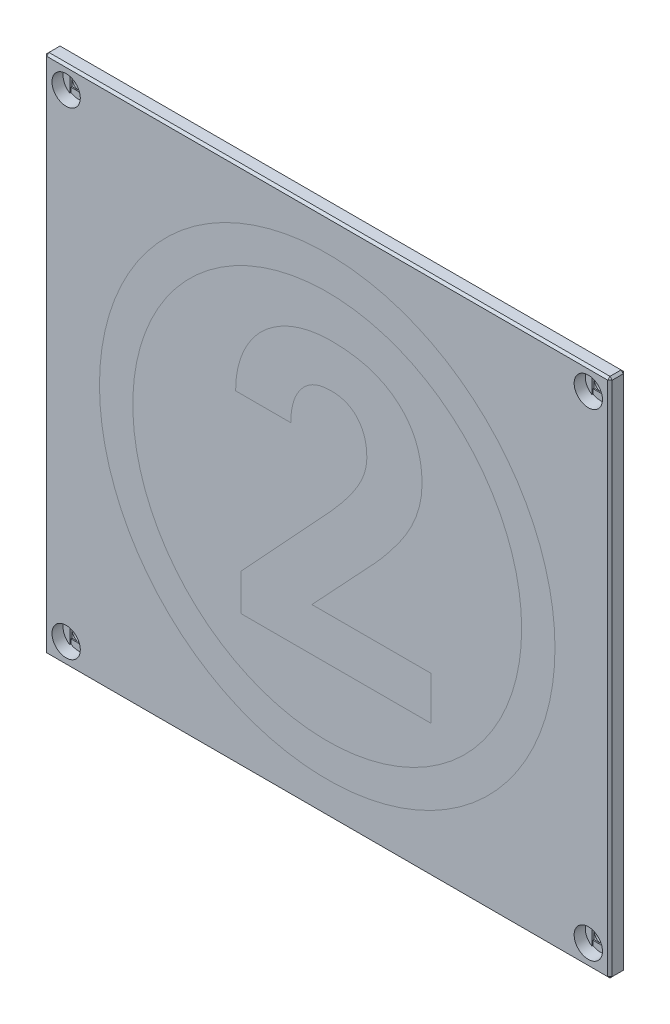
from build123d import *

# Parameters (mm, degrees)
SKETCH2_W               = 101.8
SKETCH2_H               = 93.8
SKETCH2_R               = 1.35
BOSS_EXTRUDE1_DEPTH     = 2.8
SKETCH3_R               = 2.55
CUT_EXTRUDE1_DEPTH      = 2
CUT_EXTRUDE2_DEPTH      = 0.2
SKETCH5_W               = 2.7
SKETCH5_H               = 2.7
CUT_EXTRUDE3_DEPTH      = 0.2
MIRROR2_COPY_1_DEPTH    = 0.2
MIRROR2_COPY_2_SKETCH_W = 2.7
MIRROR2_COPY_2_SKETCH_H = 2.7
MIRROR2_COPY_2_DEPTH    = 0.2
CHAMFER1_SIZE           = 0.4
SKETCH6_W               = 81.8
SKETCH6_H               = 73.8
CUT_EXTRUDE4_DEPTH      = 1.2
SKETCH7_R               = 41
SKETCH7_R_2             = 35
CUT_EXTRUDE5_DEPTH      = 1
SKETCH7_2_R             = 41
SKETCH7_2_R_2           = 35
BOSS_EXTRUDE2_DEPTH     = 1
CUT_EXTRUDE6_DEPTH      = 1
BOSS_EXTRUDE3_DEPTH     = 1


with BuildPart() as part:
    # Sketch2 → Boss-Extrude1 (new body)
    with BuildSketch(Plane.XY):
        with Locations((0, -6)):
            Rectangle(SKETCH2_W, SKETCH2_H)
        with Locations((-47, 37)):
            Circle(SKETCH2_R, mode=Mode.SUBTRACT)
        with Locations((47, 37)):
            Circle(SKETCH2_R, mode=Mode.SUBTRACT)
        with Locations((47, -49)):
            Circle(SKETCH2_R, mode=Mode.SUBTRACT)
        with Locations((-47, -49)):
            Circle(SKETCH2_R, mode=Mode.SUBTRACT)
    extrude(amount=BOSS_EXTRUDE1_DEPTH)

    # Sketch3 → Cut-Extrude1 (cut)
    with BuildSketch(Plane.XY.offset(2.8)):
        with Locations((-47, 37)):
            Circle(SKETCH3_R)
        with Locations((47, 37)):
            Circle(SKETCH3_R)
        with Locations((47, -49)):
            Circle(SKETCH3_R)
        with Locations((-47, -49)):
            Circle(SKETCH3_R)
    extrude(amount=-CUT_EXTRUDE1_DEPTH, mode=Mode.SUBTRACT)

    # Sketch4 → Cut-Extrude2 (cut)
    with BuildSketch(Plane.XY.offset(0.8)):
        with BuildLine():
            Line((-48.35, 34.836669235), (-48.35, 39.163330765))
            ThreePointArc((-48.35, 39.163330765), (-47, 39.55), (-45.65, 39.163330765))
            Line((-45.65, 39.163330765), (-45.65, 34.836669235))
            ThreePointArc((-45.65, 34.836669235), (-47, 34.45), (-48.35, 34.836669235))
        make_face()
    cut_extrude2 = extrude(amount=-CUT_EXTRUDE2_DEPTH, mode=Mode.SUBTRACT)

    # Sketch5 → Cut-Extrude3 (cut)
    with BuildSketch(Plane.XY.offset(0.6)):
        with Locations((-47, 37)):
            Rectangle(SKETCH5_W, SKETCH5_H)
    cut_extrude3 = extrude(amount=-CUT_EXTRUDE3_DEPTH, mode=Mode.SUBTRACT)

    # Mirror1: Cut-Extrude2, Cut-Extrude3 across plane
    add(cut_extrude2.mirror(Plane.ZX.offset(-6)), mode=Mode.SUBTRACT)
    add(cut_extrude3.mirror(Plane.ZX.offset(-6)), mode=Mode.SUBTRACT)

    # Mirror2: Cut-Extrude2, Cut-Extrude3 across plane
    add(cut_extrude2.mirror(Plane(origin=(0, 0, 0), x_dir=(0, 0, 1), z_dir=(1, 0, 0))), mode=Mode.SUBTRACT)
    add(cut_extrude3.mirror(Plane(origin=(0, 0, 0), x_dir=(0, 0, 1), z_dir=(1, 0, 0))), mode=Mode.SUBTRACT)

    # Mirror2 copy 1 sketch → Mirror2 copy 1 (cut)
    with BuildSketch(Plane(origin=(0, -12, 0.8), x_dir=(-1, 0, 0), z_dir=(0, 0, 1))):
        with BuildLine():
            Line((-48.35, 34.836669235), (-48.35, 39.163330765))
            ThreePointArc((-48.35, 39.163330765), (-47, 39.55), (-45.65, 39.163330765))
            Line((-45.65, 39.163330765), (-45.65, 34.836669235))
            ThreePointArc((-45.65, 34.836669235), (-47, 34.45), (-48.35, 34.836669235))
        make_face()
    extrude(amount=-MIRROR2_COPY_1_DEPTH, mode=Mode.SUBTRACT)

    # Mirror2 copy 2 sketch → Mirror2 copy 2 (cut)
    with BuildSketch(Plane(origin=(0, -12, 0.6), x_dir=(-1, 0, 0), z_dir=(0, 0, 1))):
        with Locations((-47, 37)):
            Rectangle(MIRROR2_COPY_2_SKETCH_W, MIRROR2_COPY_2_SKETCH_H)
    extrude(amount=-MIRROR2_COPY_2_DEPTH, mode=Mode.SUBTRACT)

    # Chamfer1
    chamfer1_edges = [part.edges().sort_by_distance(p)[0] for p in [
        (50.9, -6, 2.8),
        (0, 40.9, 2.8),
        (-50.9, -6, 2.8),
        (0, 40.9, 0),
        (50.9, -6, 0),
        (0, -52.9, 0),
        (-50.9, -6, 0),
        (-50.9, 40.9, 1.4),
        (50.9, 40.9, 1.4),
        (50.9, -52.9, 1.4),
        (-50.9, -52.9, 1.4),
        (0, -52.9, 2.8),
    ]]
    chamfer(chamfer1_edges, length=CHAMFER1_SIZE)

    # Sketch6 → Cut-Extrude4 (cut)
    with BuildSketch(Plane(origin=(0, 0, 0), x_dir=(-1, 0, 0), z_dir=(0, 0, -1))):
        with Locations((0, -6)):
            Rectangle(SKETCH6_W, SKETCH6_H)
    extrude(amount=-CUT_EXTRUDE4_DEPTH, mode=Mode.SUBTRACT)

    # Sketch7 → Cut-Extrude5 (cut)
    with BuildSketch(Plane.XY.offset(2.8)):
        with Locations((0, -6)):
            Circle(SKETCH7_R)
        with Locations((0, -6)):
            Circle(SKETCH7_R_2, mode=Mode.SUBTRACT)
    extrude(amount=-CUT_EXTRUDE5_DEPTH, mode=Mode.SUBTRACT)

    # Sketch8 → Cut-Extrude6 (cut)
    with BuildSketch(Plane.XY.offset(2.8)):
        with BuildLine():
            Line((18.671022727, -28.9), (-15.501055195, -28.9))
            Line((-15.501055195, -28.9), (-15.501055195, -22.274594156))
            Line((-15.501055195, -22.274594156), (0.63125, -4.884172078))
            add(Edge.make_bspline(
                [(0.63125, -4.884172078), (1.153277451, -4.292855043), (2.146557383, -3.167735389), (3.489118969, -1.506272711), (4.614642881, 0.038757574), (5.531438955, 1.477799135), (6.254834728, 2.841439855), (6.758035318, 4.1695038), (7.069448153, 5.467413282), (7.113481554, 6.32572019), (7.134902597, 6.743262987)],
                knots=[0, 0, 0, 0, 0.002366131, 0.004502121, 0.006405807, 0.008097562, 0.009617785, 0.011027364, 0.012349086, 0.013601174, 0.013601174, 0.013601174, 0.013601174], degree=3))
            add(Edge.make_bspline(
                [(7.134902597, 6.743262987), (7.118445512, 7.276005414), (7.087090374, 8.291021839), (6.769786109, 9.72439361), (6.241621668, 10.984152827), (5.60733002, 11.874698209), (5.028302195, 12.495851442), (4.530064095, 12.883158254), (3.995471939, 13.214394751), (3.418655987, 13.500854707), (2.788730275, 13.690966972), (2.122500599, 13.850084328), (1.408201929, 13.940647127), (0.915581702, 13.951532569), (0.661688312, 13.957142857)],
                knots=[0, 0, 0, 0, 0.001596166, 0.003041123, 0.004377369, 0.005666563, 0.006298071, 0.006919225, 0.007552686, 0.008183461, 0.008844439, 0.009521268, 0.010237342, 0.010998908, 0.010998908, 0.010998908, 0.010998908], degree=3))
            add(Edge.make_bspline(
                [(0.661688312, 13.957142857), (0.387329122, 13.949122126), (-0.146819306, 13.933506608), (-0.925115272, 13.818488237), (-1.657002545, 13.638358111), (-2.34656322, 13.3833698), (-2.99118454, 13.045988701), (-3.586094326, 12.627916029), (-4.144968715, 12.14576162), (-4.64669302, 11.586413684), (-5.102990563, 10.973785534), (-5.488156761, 10.302627713), (-5.829857506, 9.59447204), (-6.084904505, 8.827753466), (-6.304005462, 8.022940946), (-6.451792588, 7.170389323), (-6.546263196, 6.271919424), (-6.556889942, 5.657882139), (-6.562337662, 5.343100649)],
                knots=[0, 0, 0, 0, 0.000822836, 0.001601975, 0.002354977, 0.003080548, 0.003802135, 0.004531102, 0.005257453, 0.006011616, 0.006780715, 0.007544643, 0.008329836, 0.009135222, 0.0099646, 0.010830355, 0.011727869, 0.012671948, 0.012671948, 0.012671948, 0.012671948], degree=3))
            Line((-6.562337662, 5.343100649), (-16.495373377, 5.343100649))
            add(Edge.make_bspline(
                [(-16.495373377, 5.343100649), (-16.472833745, 6.089317638), (-16.428310573, 7.563341142), (-15.990087182, 9.712803635), (-15.323734547, 11.77162153), (-14.366953591, 13.70697381), (-13.160132284, 15.489920318), (-11.730459888, 17.097573105), (-10.051815444, 18.468784007), (-8.501752801, 19.449883434), (-7.166848132, 20.116905895), (-6.119646707, 20.555248133), (-5.039721957, 20.917594334), (-3.930506595, 21.227840696), (-2.783114737, 21.455409519), (-1.605298826, 21.630686517), (-0.39538628, 21.734275665), (0.421368014, 21.74428947), (0.834172078, 21.749350649)],
                knots=[0, 0, 0, 0, 0.002236036, 0.004416906, 0.006553763, 0.008713645, 0.010869232, 0.012995948, 0.01514333, 0.017350242, 0.018484611, 0.019617072, 0.020752892, 0.02189994, 0.023069958, 0.024259478, 0.02547112, 0.026709319, 0.026709319, 0.026709319, 0.026709319], degree=3))
            add(Edge.make_bspline(
                [(0.834172078, 21.749350649), (1.456907098, 21.737646404), (2.671022468, 21.714827221), (4.440562578, 21.538104219), (6.105120302, 21.263234511), (7.660848296, 20.855642003), (9.106919089, 20.326393159), (10.451070485, 19.688335577), (11.690955571, 18.93665069), (12.806890963, 18.056894891), (13.816455567, 17.089092945), (14.685863549, 16.007982115), (15.431503, 14.840733282), (16.033035825, 13.567820636), (16.497850687, 12.202229349), (16.834128553, 10.744393474), (17.024495809, 9.190124376), (17.053185494, 8.123647518), (17.067938312, 7.575243506)],
                knots=[0, 0, 0, 0, 0.001867875, 0.003641703, 0.005329742, 0.006924456, 0.008458767, 0.009942772, 0.011381838, 0.012798519, 0.014197689, 0.015568352, 0.016950384, 0.018343655, 0.019781111, 0.021270136, 0.022824346, 0.024469548, 0.024469548, 0.024469548, 0.024469548], degree=3))
            add(Edge.make_bspline(
                [(17.067938312, 7.575243506), (17.043098771, 6.95473273), (16.992757545, 5.697170305), (16.619494629, 3.806235067), (16.016153042, 1.897838615), (15.309531335, 0.31296178), (14.629099278, -0.985995249), (14.018070175, -2.011350852), (13.312994087, -3.069775085), (12.545269606, -4.186251153), (11.666914823, -5.32178064), (10.721490134, -6.516408603), (9.691781913, -7.752866399), (8.953838352, -8.57302218), (8.575649351, -8.993344156)],
                knots=[0, 0, 0, 0, 0.001860725, 0.00377105, 0.005760567, 0.007854945, 0.008966858, 0.010158798, 0.011433578, 0.012781789, 0.014222572, 0.015738998, 0.017352452, 0.019048582, 0.019048582, 0.019048582, 0.019048582], degree=3))
            Line((8.575649351, -8.993344156), (-2.757548701, -21.107792208))
            Line((-2.757548701, -21.107792208), (18.671022727, -21.107792208))
            Line((18.671022727, -21.107792208), (18.671022727, -28.9))
        make_face()
    extrude(amount=-CUT_EXTRUDE6_DEPTH, mode=Mode.SUBTRACT)


with BuildPart() as body_2:
    # Sketch7_2 → Boss-Extrude2 (new body)
    with BuildSketch(Plane.XY.offset(2.8)):
        with Locations((0, -6)):
            Circle(SKETCH7_2_R)
        with Locations((0, -6)):
            Circle(SKETCH7_2_R_2, mode=Mode.SUBTRACT)
    extrude(amount=-BOSS_EXTRUDE2_DEPTH)


with BuildPart() as body_3:
    # Sketch8_2 → Boss-Extrude3 (new body)
    with BuildSketch(Plane.XY.offset(2.8)):
        with BuildLine():
            Line((18.671022727, -28.9), (-15.501055195, -28.9))
            Line((-15.501055195, -28.9), (-15.501055195, -22.274594156))
            Line((-15.501055195, -22.274594156), (0.63125, -4.884172078))
            add(Edge.make_bspline(
                [(0.63125, -4.884172078), (1.153277451, -4.292855043), (2.146557383, -3.167735389), (3.489118969, -1.506272711), (4.614642881, 0.038757574), (5.531438955, 1.477799135), (6.254834728, 2.841439855), (6.758035318, 4.1695038), (7.069448153, 5.467413282), (7.113481554, 6.32572019), (7.134902597, 6.743262987)],
                knots=[0, 0, 0, 0, 0.002366131, 0.004502121, 0.006405807, 0.008097562, 0.009617785, 0.011027364, 0.012349086, 0.013601174, 0.013601174, 0.013601174, 0.013601174], degree=3))
            add(Edge.make_bspline(
                [(7.134902597, 6.743262987), (7.118445512, 7.276005414), (7.087090374, 8.291021839), (6.769786109, 9.72439361), (6.241621668, 10.984152827), (5.60733002, 11.874698209), (5.028302195, 12.495851442), (4.530064095, 12.883158254), (3.995471939, 13.214394751), (3.418655987, 13.500854707), (2.788730275, 13.690966972), (2.122500599, 13.850084328), (1.408201929, 13.940647127), (0.915581702, 13.951532569), (0.661688312, 13.957142857)],
                knots=[0, 0, 0, 0, 0.001596166, 0.003041123, 0.004377369, 0.005666563, 0.006298071, 0.006919225, 0.007552686, 0.008183461, 0.008844439, 0.009521268, 0.010237342, 0.010998908, 0.010998908, 0.010998908, 0.010998908], degree=3))
            add(Edge.make_bspline(
                [(0.661688312, 13.957142857), (0.387329122, 13.949122126), (-0.146819306, 13.933506608), (-0.925115272, 13.818488237), (-1.657002545, 13.638358111), (-2.34656322, 13.3833698), (-2.99118454, 13.045988701), (-3.586094326, 12.627916029), (-4.144968715, 12.14576162), (-4.64669302, 11.586413684), (-5.102990563, 10.973785534), (-5.488156761, 10.302627713), (-5.829857506, 9.59447204), (-6.084904505, 8.827753466), (-6.304005462, 8.022940946), (-6.451792588, 7.170389323), (-6.546263196, 6.271919424), (-6.556889942, 5.657882139), (-6.562337662, 5.343100649)],
                knots=[0, 0, 0, 0, 0.000822836, 0.001601975, 0.002354977, 0.003080548, 0.003802135, 0.004531102, 0.005257453, 0.006011616, 0.006780715, 0.007544643, 0.008329836, 0.009135222, 0.0099646, 0.010830355, 0.011727869, 0.012671948, 0.012671948, 0.012671948, 0.012671948], degree=3))
            Line((-6.562337662, 5.343100649), (-16.495373377, 5.343100649))
            add(Edge.make_bspline(
                [(-16.495373377, 5.343100649), (-16.472833745, 6.089317638), (-16.428310573, 7.563341142), (-15.990087182, 9.712803635), (-15.323734547, 11.77162153), (-14.366953591, 13.70697381), (-13.160132284, 15.489920318), (-11.730459888, 17.097573105), (-10.051815444, 18.468784007), (-8.501752801, 19.449883434), (-7.166848132, 20.116905895), (-6.119646707, 20.555248133), (-5.039721957, 20.917594334), (-3.930506595, 21.227840696), (-2.783114737, 21.455409519), (-1.605298826, 21.630686517), (-0.39538628, 21.734275665), (0.421368014, 21.74428947), (0.834172078, 21.749350649)],
                knots=[0, 0, 0, 0, 0.002236036, 0.004416906, 0.006553763, 0.008713645, 0.010869232, 0.012995948, 0.01514333, 0.017350242, 0.018484611, 0.019617072, 0.020752892, 0.02189994, 0.023069958, 0.024259478, 0.02547112, 0.026709319, 0.026709319, 0.026709319, 0.026709319], degree=3))
            add(Edge.make_bspline(
                [(0.834172078, 21.749350649), (1.456907098, 21.737646404), (2.671022468, 21.714827221), (4.440562578, 21.538104219), (6.105120302, 21.263234511), (7.660848296, 20.855642003), (9.106919089, 20.326393159), (10.451070485, 19.688335577), (11.690955571, 18.93665069), (12.806890963, 18.056894891), (13.816455567, 17.089092945), (14.685863549, 16.007982115), (15.431503, 14.840733282), (16.033035825, 13.567820636), (16.497850687, 12.202229349), (16.834128553, 10.744393474), (17.024495809, 9.190124376), (17.053185494, 8.123647518), (17.067938312, 7.575243506)],
                knots=[0, 0, 0, 0, 0.001867875, 0.003641703, 0.005329742, 0.006924456, 0.008458767, 0.009942772, 0.011381838, 0.012798519, 0.014197689, 0.015568352, 0.016950384, 0.018343655, 0.019781111, 0.021270136, 0.022824346, 0.024469548, 0.024469548, 0.024469548, 0.024469548], degree=3))
            add(Edge.make_bspline(
                [(17.067938312, 7.575243506), (17.043098771, 6.95473273), (16.992757545, 5.697170305), (16.619494629, 3.806235067), (16.016153042, 1.897838615), (15.309531335, 0.31296178), (14.629099278, -0.985995249), (14.018070175, -2.011350852), (13.312994087, -3.069775085), (12.545269606, -4.186251153), (11.666914823, -5.32178064), (10.721490134, -6.516408603), (9.691781913, -7.752866399), (8.953838352, -8.57302218), (8.575649351, -8.993344156)],
                knots=[0, 0, 0, 0, 0.001860725, 0.00377105, 0.005760567, 0.007854945, 0.008966858, 0.010158798, 0.011433578, 0.012781789, 0.014222572, 0.015738998, 0.017352452, 0.019048582, 0.019048582, 0.019048582, 0.019048582], degree=3))
            Line((8.575649351, -8.993344156), (-2.757548701, -21.107792208))
            Line((-2.757548701, -21.107792208), (18.671022727, -21.107792208))
            Line((18.671022727, -21.107792208), (18.671022727, -28.9))
        make_face()
    extrude(amount=-BOSS_EXTRUDE3_DEPTH)


solid = Compound([part.part, body_2.part, body_3.part])
